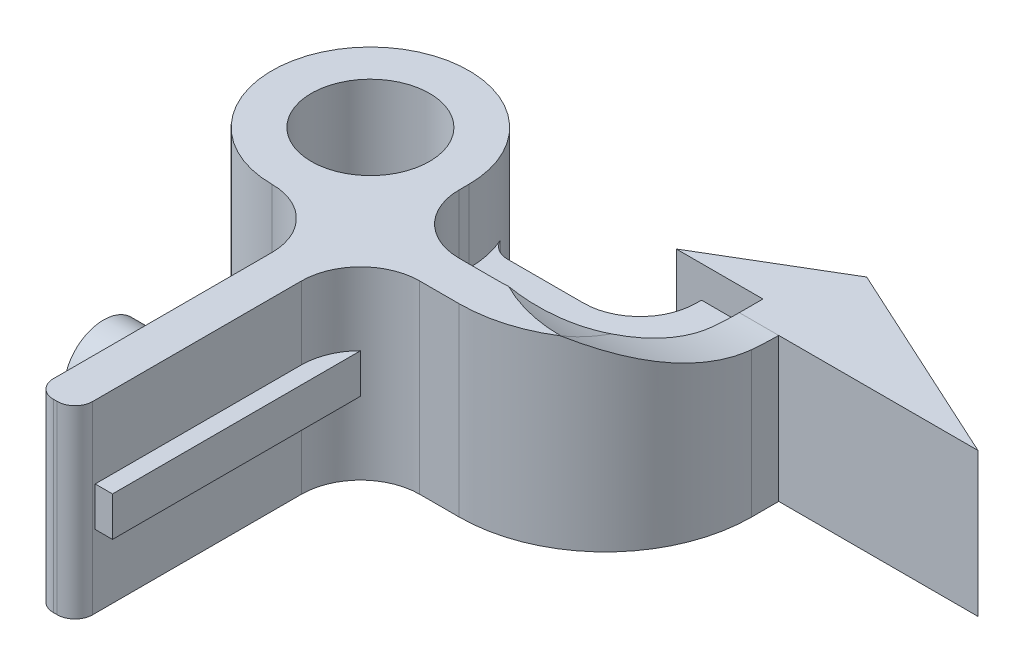
from build123d import *

# Parameters (mm, degrees)
SKETCH1_R           = 3
BOSS_EXTRUDE1_DEPTH = 9.38
BOSS_EXTRUDE2_DEPTH = 1
SKETCH5_R           = 2
BOSS_EXTRUDE3_DEPTH = 4
BOSS_EXTRUDE4_DEPTH = 1
CUT_EXTRUDE1_DEPTH  = 15
SKETCH8_W           = 1.762177923
SKETCH8_H           = 2.08
CUT_EXTRUDE2_DEPTH  = 5
CUT_REVOLVE2_ANGLE  = 180


with BuildPart() as part:
    # Sketch1 → Boss-Extrude1 (new body)
    with BuildSketch(Plane(origin=(0, 0, 0), x_dir=(1, 0, 0), z_dir=(0, 1, 0))):
        with BuildLine():
            Line((3, -8), (3, -19.1))
            ThreePointArc((3, -19.1), (3.263603897, -19.736396103), (3.9, -20))
            Line((3.9, -20), (4.1, -20))
            ThreePointArc((4.1, -20), (4.736396103, -19.736396103), (5, -19.1))
            Line((5, -19.1), (5, -8.5))
            ThreePointArc((5, -8.5), (5.878679656, -6.378679656), (8, -5.5))
            Line((8, -5.5), (10, -5.5))
            ThreePointArc((10, -5.5), (15.253803384, -3.323803384), (17.43, 1.93))
            Line((17.43, 1.93), (17.43, 3.3))
            Line((17.43, 3.3), (27.54785059, 3.3))
            Line((27.54785059, 3.3), (17.097491745, 8.1))
            Line((17.097491745, 8.1), (11.03, 4.5))
            Line((11.03, 4.5), (15.43, 4.5))
            Line((15.43, 4.5), (15.43, 1.93))
            ThreePointArc((15.43, 1.93), (13.839589822, -1.909589822), (10, -3.5))
            Line((10, -3.5), (8, -3.5))
            ThreePointArc((8, -3.5), (5.878679656, -2.621320344), (5, -0.5))
            Line((5, -0.5), (5, 0))
            ThreePointArc((5, 0), (-3.535533906, 3.535533906), (0, -5))
            ThreePointArc((0, -5), (2.121320344, -5.878679656), (3, -8))
        make_face()
        Circle(SKETCH1_R, mode=Mode.SUBTRACT)
    extrude(amount=BOSS_EXTRUDE1_DEPTH)

    # Sketch3 → Boss-Extrude2 (add, symmetric)
    with BuildSketch(Plane(origin=(0, 4.69, 0), x_dir=(1, 0, 0), z_dir=(0, 1, 0))):
        with BuildLine():
            Line((9.443635769, 1.375812361), (5.601654611, 1.375812361))
            ThreePointArc((5.601654611, 1.375812361), (4.981779837, 1.558852726), (4.560762938, 2.04925387))
            ThreePointArc((4.560762938, 2.04925387), (4.888957695, 1.047899163), (5, 0))
            Line((5, 0), (5, -0.5))
            ThreePointArc((5, -0.5), (5.878679656, -2.621320344), (8, -3.5))
            Line((8, -3.5), (10, -3.5))
            ThreePointArc((10, -3.5), (13.839589822, -1.909589822), (15.43, 1.93))
            Line((15.43, 1.93), (15.43, 4.5))
            Line((15.43, 4.5), (12.309861007, 4.5))
            Line((12.309861007, 4.5), (12.309861007, 4.242037598))
            ThreePointArc((12.309861007, 4.242037598), (11.470363071, 2.215310296), (9.443635769, 1.375812361))
        make_face()
    extrude(amount=BOSS_EXTRUDE2_DEPTH, both=True)

    # Sketch5 → Boss-Extrude3 (add)
    with BuildSketch(Plane.ZY.offset(-3)):
        with Locations((12.55, 4.69)):
            Circle(SKETCH5_R)
    extrude(amount=BOSS_EXTRUDE3_DEPTH)

    # Sketch6 → Boss-Extrude4 (add, symmetric)
    with BuildSketch(Plane(origin=(0, 4.69, 0), x_dir=(1, 0, 0), z_dir=(0, 1, 0))):
        with BuildLine():
            ThreePointArc((5, -8.5), (5.228361402, -7.351949703), (5.878679656, -6.378679656))
            Line((5.878679656, -6.378679656), (5.878679656, -18.972831199))
            Line((5.878679656, -18.972831199), (5, -18.972831199))
            Line((5, -18.972831199), (5, -8.5))
        make_face()
    extrude(amount=BOSS_EXTRUDE4_DEPTH, both=True)

    # Sketch7 → Cut-Extrude1 (cut)
    with BuildSketch(Plane(origin=(14, 0, 0), x_dir=(0, 0, -1), z_dir=(1, 0, 0))):
        with BuildLine():
            Line((-4.338573914, 9.38), (3.3, 22.365916212))
            Line((3.3, 22.365916212), (8.1, 10.195783218))
            Line((8.1, 10.195783218), (8.1, 7.3))
            Line((8.1, 7.3), (3.3, 7.3))
            ThreePointArc((3.3, 7.3), (-0.658352291, 7.829297677), (-4.338573914, 9.38))
        make_face()
    extrude(amount=CUT_EXTRUDE1_DEPTH, mode=Mode.SUBTRACT)

    # Sketch8 → Cut-Extrude2 (cut)
    with BuildSketch(Plane(origin=(14, 0, 0), x_dir=(0, 0, -1), z_dir=(1, 0, 0))):
        with Locations((5.381088961, 8.34)):
            Rectangle(SKETCH8_W, SKETCH8_H)
    extrude(amount=-CUT_EXTRUDE2_DEPTH, mode=Mode.SUBTRACT)

    # Sketch12 → Cut-Revolve2 (revolve, cut)
    with BuildSketch(Plane(origin=(14, 0, 0), x_dir=(0, 0, -1), z_dir=(1, 0, 0))):
        with BuildLine():
            Line((-1.74217919, 9.38), (-1.74217919, 8.168794661))
            ThreePointArc((-1.74217919, 8.168794661), (-3.065452427, 8.710776275), (-4.331381637, 9.375772039))
            Line((-4.331381637, 9.375772039), (-4.331381637, 10.213200203))
            Line((-4.331381637, 10.213200203), (-1.74217919, 10.213200203))
            Line((-1.74217919, 10.213200203), (-1.74217919, 9.38))
        make_face()
    revolve(axis=Axis((14, 22.365916212, -3.3), (0, -1, 0)), revolution_arc=CUT_REVOLVE2_ANGLE, mode=Mode.SUBTRACT)


solid = part.part
